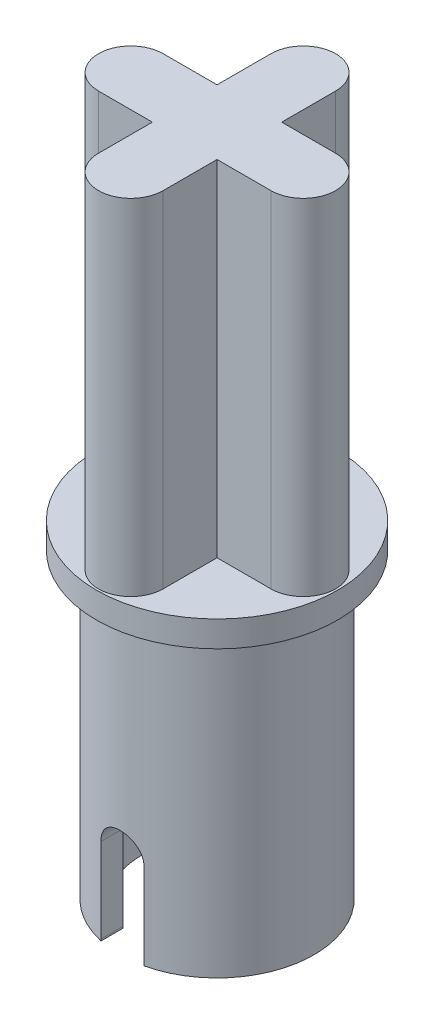
from build123d import *

# Parameters (mm, degrees)
SKETCH1_R           = 2.8
BOSS_EXTRUDE1_DEPTH = 0.6
SKETCH2_W           = 1.5
SKETCH2_H           = 1.5
BOSS_EXTRUDE2_DEPTH = 8
SKETCH6_R           = 2.25
BOSS_EXTRUDE3_DEPTH = 7
CUT_EXTRUDE1_DEPTH  = 103.8
SKETCH9_R           = 1.75
CUT_EXTRUDE3_DEPTH  = 10


with BuildPart() as part:
    # Sketch1 → Boss-Extrude1 (new body)
    with BuildSketch(Plane(origin=(0, 0, 0), x_dir=(1, 0, 0), z_dir=(0, 1, 0))):
        Circle(SKETCH1_R)
    extrude(amount=BOSS_EXTRUDE1_DEPTH)

    # Sketch2 → Boss-Extrude2 (add)
    with BuildSketch(Plane(origin=(0, 0.6, 0), x_dir=(1, 0, 0), z_dir=(0, 1, 0))):
        with BuildLine():
            Line((0.75, 0.75), (0.75, -0.75))
            Line((0.75, -0.75), (2, -0.75))
            ThreePointArc((2, -0.75), (2.75, 0), (2, 0.75))
            Line((2, 0.75), (0.75, 0.75))
        make_face()
        with BuildLine():
            Line((-0.75, 2), (-0.75, 0.75))
            Line((-0.75, 0.75), (0.75, 0.75))
            Line((0.75, 0.75), (0.75, 2))
            ThreePointArc((0.75, 2), (0, 2.75), (-0.75, 2))
        make_face()
        Rectangle(SKETCH2_W, SKETCH2_H)
        with BuildLine():
            Line((-2, -0.75), (-0.75, -0.75))
            Line((-0.75, -0.75), (-0.75, 0.75))
            Line((-0.75, 0.75), (-2, 0.75))
            ThreePointArc((-2, 0.75), (-2.75, 0), (-2, -0.75))
        make_face()
        with BuildLine():
            Line((-0.75, -0.75), (-0.75, -2))
            ThreePointArc((-0.75, -2), (0, -2.75), (0.75, -2))
            Line((0.75, -2), (0.75, -0.75))
            Line((0.75, -0.75), (-0.75, -0.75))
        make_face()
    extrude(amount=BOSS_EXTRUDE2_DEPTH)

    # Sketch6 → Boss-Extrude3 (add)
    with BuildSketch(Plane.XZ):
        Circle(SKETCH6_R)
    extrude(amount=BOSS_EXTRUDE3_DEPTH)

    # Sketch7 → Cut-Extrude1 (cut, through all)
    with BuildSketch(Plane.XY.offset(100)):
        with BuildLine():
            Line((0.5, -5), (0.5, -6.962153423))
            ThreePointArc((0.5, -6.962153423), (0, -7.462153423), (-0.5, -6.962153423))
            Line((-0.5, -6.962153423), (-0.5, -5))
            ThreePointArc((-0.5, -5), (0, -4.5), (0.5, -5))
        make_face()
    extrude(amount=-CUT_EXTRUDE1_DEPTH, mode=Mode.SUBTRACT)

    # Sketch9 → Cut-Extrude3 (cut)
    with BuildSketch(Plane(origin=(0, -10, 0), x_dir=(1, 0, 0), z_dir=(0, 1, 0))):
        Circle(SKETCH9_R)
    extrude(amount=CUT_EXTRUDE3_DEPTH, mode=Mode.SUBTRACT)


solid = part.part
